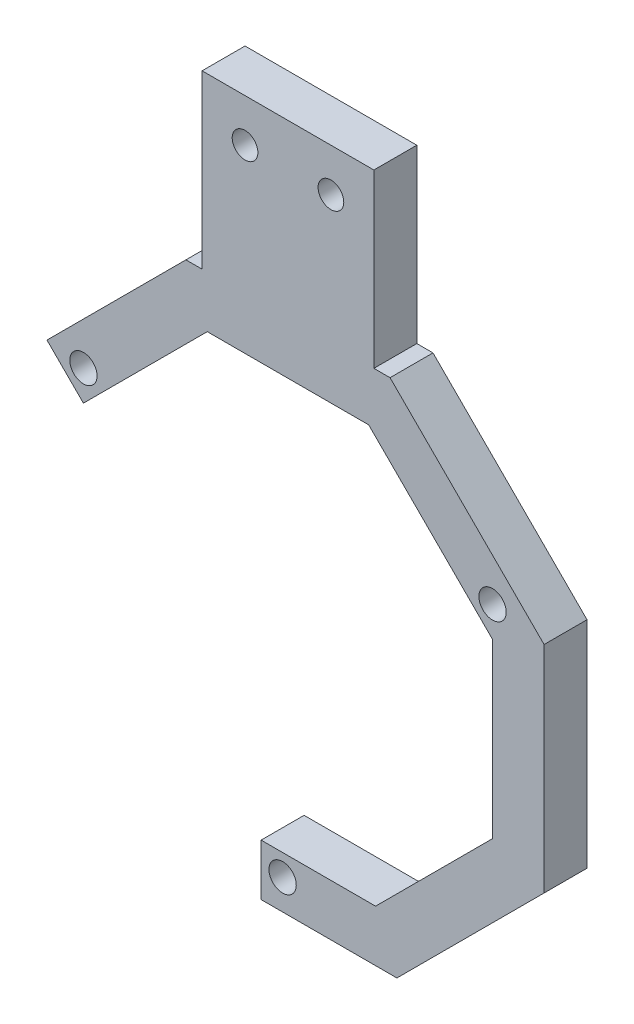
from build123d import *

# Parameters (mm, degrees)
BOSS_EXTRUDE1_DEPTH    = 6.35
F_10_32_TAPPED_HOLE1_D = 4.0386
F_10_32_TAPPED_HOLE2_D = 4.0386
F_6_CLEARANCE_HOLE1_D  = 3.7973


with BuildPart() as part:
    # Sketch1 → Boss-Extrude1 (new body)
    with BuildSketch(Plane.XY):
        Polygon((-35.6340909, 17.237993597), (-15.089584497, 37.7825), (-12.7, 37.7825), (-12.7, 63.1825), (12.7, 63.1825), (12.7, 37.7825), (15.089584497, 37.7825), (37.865937227, 15.00614727), (37.865937227, -16.815626239), (16.105313466, -38.57625), (-3.96875, -38.57625), (-3.96875, -30.95625), (12.949006121, -30.95625), (30.245937227, -13.659318894), (30.245937227, 11.849839924), (11.933277152, 30.1625), (-11.933277152, 30.1625), (-30.245937227, 11.849839924), align=None)
    extrude(amount=BOSS_EXTRUDE1_DEPTH)

    # #10-32 Tapped Hole1 (through all)
    with Locations(Plane.XY.offset(6.35)):
        with Locations((-30.245937227, 16.339967985)):
            Hole(F_10_32_TAPPED_HOLE1_D / 2)

    # #10-32 Tapped Hole2 (through all)
    with Locations(Plane.XY.offset(6.35)):
        with Locations((30.245937227, 16.339967985), (-0.79375, -34.13125)):
            Hole(F_10_32_TAPPED_HOLE2_D / 2)

    # #6 Clearance Hole1 (through all)
    with Locations(Plane(origin=(-6.35, 56.8325, 6.35), x_dir=(1, 0, 0), z_dir=(0, 0, 1))):
        with Locations((0, 0), (12.7, 0)):
            Hole(F_6_CLEARANCE_HOLE1_D / 2)


solid = part.part
